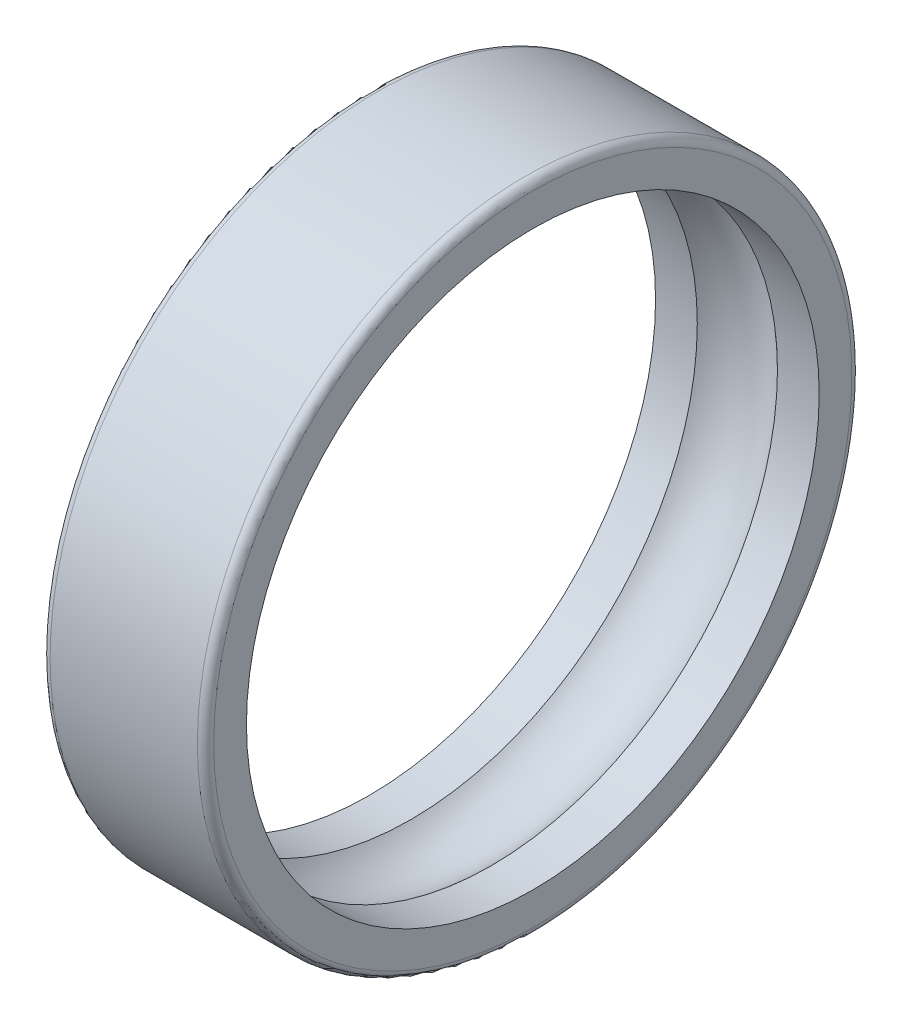
from build123d import *


with BuildPart() as part:
    # Esquisse1 → Base-Révolution (revolve)
    with BuildSketch(Plane.XY):
        with BuildLine():
            Line((0, 7), (1.020204103, 7))
            ThreePointArc((1.020204103, 7), (2, 7.4), (2.979795897, 7))
            Line((2.979795897, 7), (4, 7))
            Line((4, 7), (4, 7.8))
            ThreePointArc((4, 7.8), (3.941421356, 7.941421356), (3.8, 8))
            Line((3.8, 8), (0.2, 8))
            ThreePointArc((0.2, 8), (0.058578644, 7.941421356), (0, 7.8))
            Line((0, 7.8), (0, 7))
        make_face()
    revolve(axis=Axis((0, 0, 0), (1, 0, 0)))


solid = part.part
